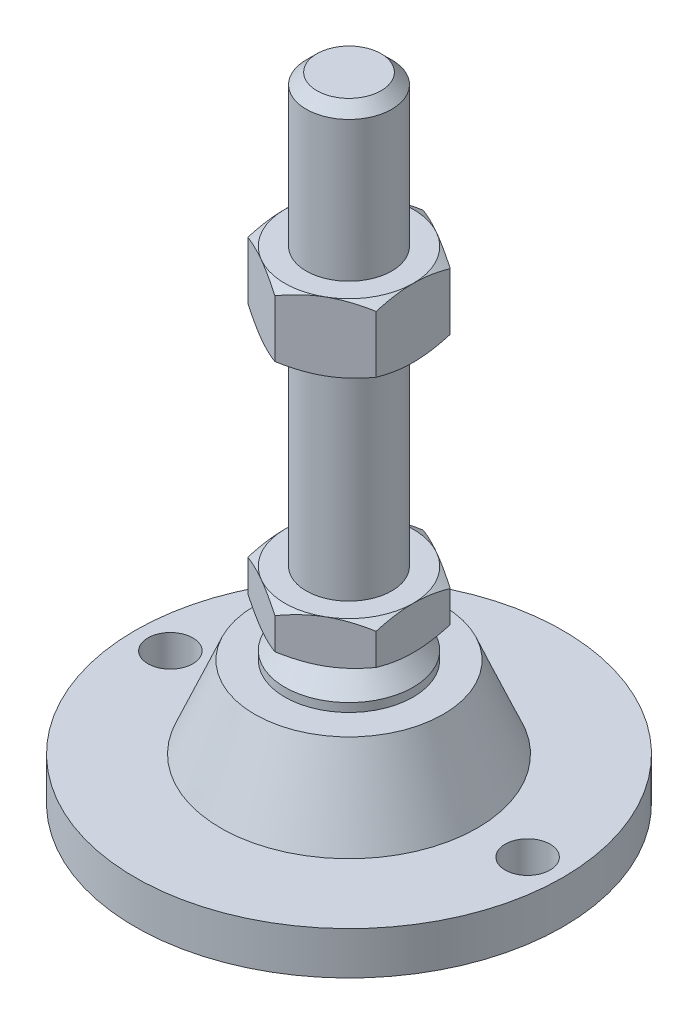
from build123d import *

# Parameters (mm, degrees)
EXTRUDE_1_DEPTH     = 10
EXTRUDE_2_DEPTH     = 16
SKETCH_5_R          = 5.25
CUT_EXTRUDE_1_DEPTH = 11


with BuildPart() as part:
    # Эскиз1 → Повернуть1 (revolve)
    with BuildSketch(Plane.XY, mode=Mode.PRIVATE) as revolve_1_sk:
        Polygon((0, 0), (-50, 0), (-50, 10), (-30, 10), (-22, 29), (-15, 29), (-15, 31), (-10, 36), (-10, 38), (-10, 48), (-10, 145.5), (-7.5, 148), (0, 148), align=None)
    revolve(revolve_1_sk.sketch.rotate(Axis((0, 0, 0), (0, 1, 0)), 180), axis=Axis((0, 0, 0), (0, 1, 0)))  # turned: the seam where the file's is

    # Эскиз2 → Бобышка-Вытянуть1 (add)
    with BuildSketch(Plane(origin=(0, 38, 0), x_dir=(1, 0, 0), z_dir=(0, 1, 0))):
        Polygon((0, 17.320508076), (-15, 8.660254038), (-15, -8.660254038), (0, -17.320508076), (15, -8.660254038), (15, 8.660254038), align=None)
    extrude(amount=EXTRUDE_1_DEPTH)

    # Эскиз3 → Бобышка-Вытянуть2 (add)
    with BuildSketch(Plane(origin=(0, 96.75, 0), x_dir=(1, 0, 0), z_dir=(0, 1, 0))):
        Polygon((15, 8.660254038), (0, 17.320508076), (-15, 8.660254038), (-15, -8.660254038), (0, -17.320508076), (15, -8.660254038), align=None)
    extrude(amount=EXTRUDE_2_DEPTH)

    # Эскиз4 → Вырез-Повернуть2 (revolve, cut)
    with BuildSketch(Plane.XY, mode=Mode.PRIVATE) as cut_revolve_2_sk:
        Polygon((-28.856406461, 112.75), (-15, 112.75), (-28.856406461, 104.75), align=None)
        Polygon((-28.856406461, 96.75), (-28.856406461, 104.75), (-15, 96.75), align=None)
        Polygon((-23.660254038, 48), (-23.660254038, 43), (-15, 48), align=None)
        Polygon((-23.660254038, 43), (-23.660254038, 38), (-15, 38), align=None)
    revolve(cut_revolve_2_sk.sketch.rotate(Axis((0, 148, 0), (0, -1, 0)), 180), axis=Axis((0, 148, 0), (0, -1, 0)), mode=Mode.SUBTRACT)  # turned: the seam where the file's is

    # Эскиз5 → Вырез-Вытянуть1 (cut, through all)
    with BuildSketch(Plane(origin=(0, 10, 0), x_dir=(1, 0, 0), z_dir=(0, 1, 0))):
        with Locations(Location((-41.75, 0, 0), (0, 0, 180))):  # turned: the seam where the file's is
            Circle(SKETCH_5_R)
        with Locations(Location((41.75, 0, 0), (0, 0, 180))):  # turned: the seam where the file's is
            Circle(SKETCH_5_R)
    extrude(amount=-CUT_EXTRUDE_1_DEPTH, mode=Mode.SUBTRACT)


solid = part.part
